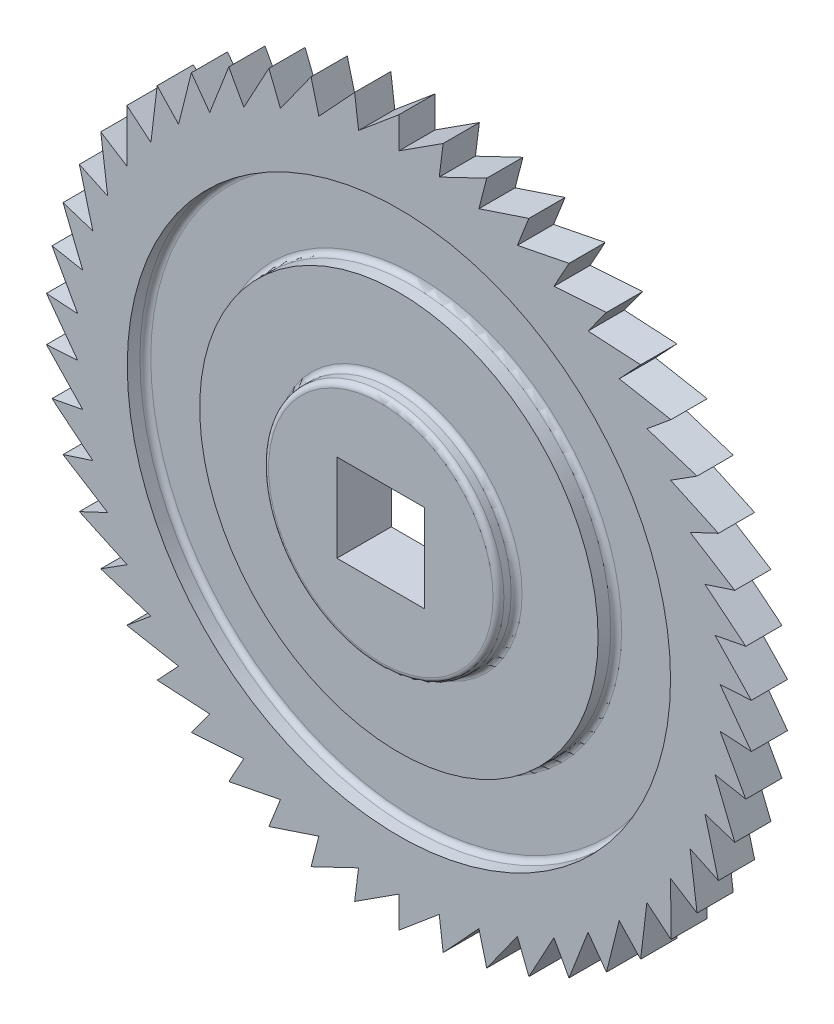
from build123d import *

# Parameters (mm, degrees)
BOSS_EXTRUDE1_DEPTH = 2
CIRPATTERN1_COUNT   = 50
SKETCH3_W           = 4.842640688
SKETCH3_H           = 4.842640688
CUT_EXTRUDE2_DEPTH  = 3
SKETCH4_R           = 15
SKETCH4_R_2         = 11
CUT_EXTRUDE3_DEPTH  = 1
SKETCH5_R           = 6.5
SKETCH5_W           = 4.842640688
SKETCH5_H           = 4.842640688
BOSS_EXTRUDE2_DEPTH = 1
FILLET1_R           = 0.3


with BuildPart() as part:
    # Sketch2 → Boss-Extrude1 (new body)
    with BuildSketch(Plane.XY):
        with BuildLine():
            Line((0, -91), (0, -89))
            Line((0, -89), (-2.618249578, -91.196972255))
            ThreePointArc((-2.618249578, -91.196972255), (1.312824143, -125.950687458), (0, -91))
        make_face()
    boss_extrude1 = extrude(amount=-BOSS_EXTRUDE1_DEPTH)

    # CirPattern1: Boss-Extrude1 ×50 about axis
    cirpattern1_axis = Axis((0, -108.5, 0), (0, 0, 1))
    for i in range(1, CIRPATTERN1_COUNT):
        add(boss_extrude1.rotate(cirpattern1_axis, i * 360 / CIRPATTERN1_COUNT))

    # Sketch3 → Cut-Extrude2 (cut, through all)
    with BuildSketch(Plane.XY):
        with Locations((0, -108.5)):
            Rectangle(SKETCH3_W, SKETCH3_H)
    extrude(amount=-CUT_EXTRUDE2_DEPTH, mode=Mode.SUBTRACT)

    # Sketch4 → Cut-Extrude3 (cut)
    with BuildSketch(Plane.XY):
        with Locations((0, -108.5)):
            Circle(SKETCH4_R)
        with Locations((0, -108.5)):
            Circle(SKETCH4_R_2, mode=Mode.SUBTRACT)
    extrude(amount=-CUT_EXTRUDE3_DEPTH, mode=Mode.SUBTRACT)

    # Sketch5 → Boss-Extrude2 (add)
    with BuildSketch(Plane.XY):
        with Locations((0, -108.5)):
            Circle(SKETCH5_R)
        with Locations((0, -108.5)):
            Rectangle(SKETCH5_W, SKETCH5_H, mode=Mode.SUBTRACT)
    extrude(amount=BOSS_EXTRUDE2_DEPTH)

    # Fillet1
    fillet1_edges = [part.edges().sort_by_distance(p)[0] for p in [
        (-15, -108.5, -1),
        (-11, -108.5, -1),
        (-6.5, -108.5, 1),
        (-6.5, -108.5, 0),
    ]]
    fillet(fillet1_edges, radius=FILLET1_R)


solid = part.part
